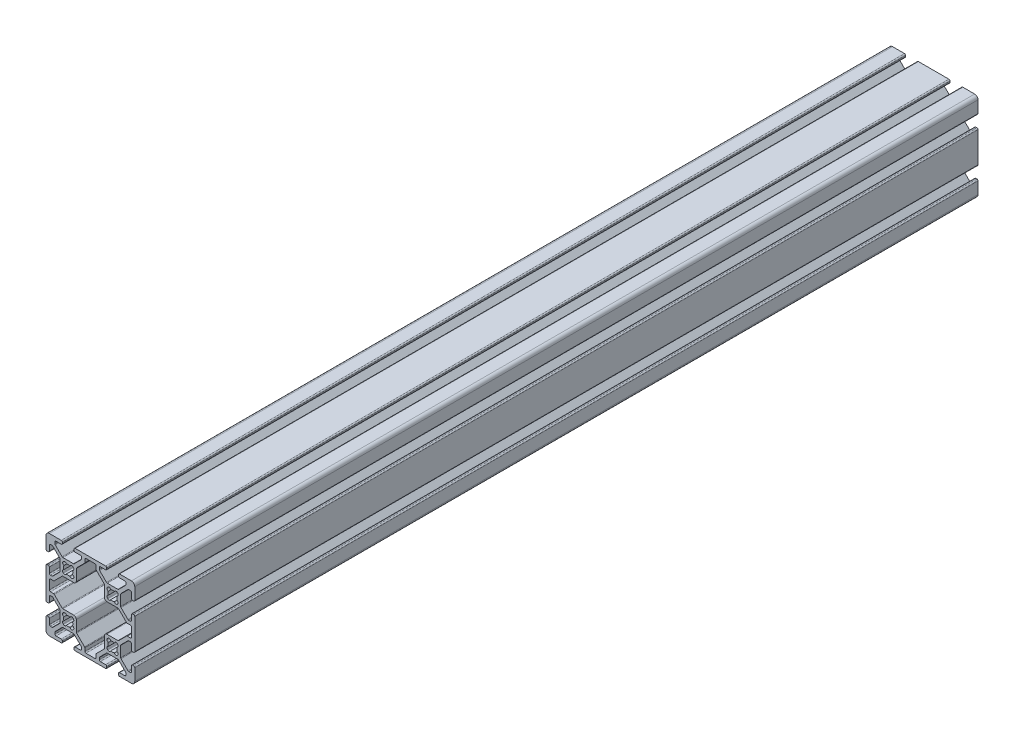
from build123d import *

# Parameters (mm, degrees)
EXTRUDE1_DEPTH = 380


with BuildPart() as part:
    # Sketch1 → Extrude1 (new body)
    with BuildSketch(Plane.XY):
        with BuildLine():
            Line((-22.383919339, -3.655), (-17.616080661, -3.655))
            ThreePointArc((-17.616080661, -3.655), (-17.421677478, -3.693669197), (-17.256870417, -3.803789755))
            Line((-17.256870417, -3.803789755), (-14.153789755, -6.906870417))
            ThreePointArc((-14.153789755, -6.906870417), (-14.043669197, -7.071677478), (-14.005, -7.266080661))
            Line((-14.005, -7.266080661), (-14.005, -7.992))
            ThreePointArc((-14.005, -7.992), (-14.153789755, -8.351210245), (-14.513, -8.5))
            Line((-14.513, -8.5), (-16.862, -8.5))
            ThreePointArc((-16.862, -8.5), (-17.221210245, -8.648789755), (-17.37, -9.008))
            Line((-17.37, -9.008), (-17.37, -9.492))
            ThreePointArc((-17.37, -9.492), (-17.221210245, -9.851210245), (-16.862, -10))
            Line((-16.862, -10), (-3.138, -10))
            ThreePointArc((-3.138, -10), (-2.778789755, -9.851210245), (-2.63, -9.492))
            Line((-2.63, -9.492), (-2.63, -9.008))
            ThreePointArc((-2.63, -9.008), (-2.778789755, -8.648789755), (-3.138, -8.5))
            Line((-3.138, -8.5), (-5.487, -8.5))
            ThreePointArc((-5.487, -8.5), (-5.846210245, -8.351210245), (-5.995, -7.992))
            Line((-5.995, -7.992), (-5.995, -7.266080661))
            ThreePointArc((-5.995, -7.266080661), (-5.956330803, -7.071677478), (-5.846210245, -6.906870417))
            Line((-5.846210245, -6.906870417), (-2.743129583, -3.803789755))
            ThreePointArc((-2.743129583, -3.803789755), (-2.578322522, -3.693669197), (-2.383919339, -3.655))
            Line((-2.383919339, -3.655), (2.383919339, -3.655))
            ThreePointArc((2.383919339, -3.655), (2.578322522, -3.693669197), (2.743129583, -3.803789755))
            Line((2.743129583, -3.803789755), (5.846210245, -6.906870417))
            ThreePointArc((5.846210245, -6.906870417), (5.956330803, -7.071677478), (5.995, -7.266080661))
            Line((5.995, -7.266080661), (5.995, -7.992))
            ThreePointArc((5.995, -7.992), (5.846210245, -8.351210245), (5.487, -8.5))
            Line((5.487, -8.5), (3.138, -8.5))
            ThreePointArc((3.138, -8.5), (2.778789755, -8.648789755), (2.63, -9.008))
            Line((2.63, -9.008), (2.63, -9.492))
            ThreePointArc((2.63, -9.492), (2.778789755, -9.851210245), (3.138, -10))
            Line((3.138, -10), (8.5, -10))
            ThreePointArc((8.5, -10), (9.560660172, -9.560660172), (10, -8.5))
            Line((10, -8.5), (10, -3.138))
            ThreePointArc((10, -3.138), (9.851210245, -2.778789755), (9.492, -2.63))
            Line((9.492, -2.63), (9.008, -2.63))
            ThreePointArc((9.008, -2.63), (8.648789755, -2.778789755), (8.5, -3.138))
            Line((8.5, -3.138), (8.5, -5.487))
            ThreePointArc((8.5, -5.487), (8.351210245, -5.846210245), (7.992, -5.995))
            Line((7.992, -5.995), (7.266080661, -5.995))
            ThreePointArc((7.266080661, -5.995), (7.071677478, -5.956330803), (6.906870417, -5.846210245))
            Line((6.906870417, -5.846210245), (3.803789755, -2.743129583))
            ThreePointArc((3.803789755, -2.743129583), (3.693669197, -2.578322522), (3.655, -2.383919339))
            Line((3.655, -2.383919339), (3.655, 2.383919339))
            ThreePointArc((3.655, 2.383919339), (3.693669197, 2.578322522), (3.803789755, 2.743129583))
            Line((3.803789755, 2.743129583), (6.906870417, 5.846210245))
            ThreePointArc((6.906870417, 5.846210245), (7.071677478, 5.956330803), (7.266080661, 5.995))
            Line((7.266080661, 5.995), (7.992, 5.995))
            ThreePointArc((7.992, 5.995), (8.351210245, 5.846210245), (8.5, 5.487))
            Line((8.5, 5.487), (8.5, 3.138))
            ThreePointArc((8.5, 3.138), (8.648789755, 2.778789755), (9.008, 2.63))
            Line((9.008, 2.63), (9.492, 2.63))
            ThreePointArc((9.492, 2.63), (9.851210245, 2.778789755), (10, 3.138))
            Line((10, 3.138), (10, 16.862))
            ThreePointArc((10, 16.862), (9.851210245, 17.221210245), (9.492, 17.37))
            Line((9.492, 17.37), (9.008, 17.37))
            ThreePointArc((9.008, 17.37), (8.648789755, 17.221210245), (8.5, 16.862))
            Line((8.5, 16.862), (8.5, 14.513))
            ThreePointArc((8.5, 14.513), (8.351210245, 14.153789755), (7.992, 14.005))
            Line((7.992, 14.005), (7.266080661, 14.005))
            ThreePointArc((7.266080661, 14.005), (7.071677478, 14.043669197), (6.906870417, 14.153789755))
            Line((6.906870417, 14.153789755), (3.803789755, 17.256870417))
            ThreePointArc((3.803789755, 17.256870417), (3.693669197, 17.421677478), (3.655, 17.616080661))
            Line((3.655, 17.616080661), (3.655, 22.383919339))
            ThreePointArc((3.655, 22.383919339), (3.693669197, 22.578322522), (3.803789755, 22.743129583))
            Line((3.803789755, 22.743129583), (6.906870417, 25.846210245))
            ThreePointArc((6.906870417, 25.846210245), (7.071677478, 25.956330803), (7.266080661, 25.995))
            Line((7.266080661, 25.995), (7.992, 25.995))
            ThreePointArc((7.992, 25.995), (8.351210245, 25.846210245), (8.5, 25.487))
            Line((8.5, 25.487), (8.5, 23.138))
            ThreePointArc((8.5, 23.138), (8.648789755, 22.778789755), (9.008, 22.63))
            Line((9.008, 22.63), (9.492, 22.63))
            ThreePointArc((9.492, 22.63), (9.851210245, 22.778789755), (10, 23.138))
            Line((10, 23.138), (10, 28.5))
            ThreePointArc((10, 28.5), (9.560660172, 29.560660172), (8.5, 30))
            Line((8.5, 30), (3.138, 30))
            ThreePointArc((3.138, 30), (2.778789755, 29.851210245), (2.63, 29.492))
            Line((2.63, 29.492), (2.63, 29.008))
            ThreePointArc((2.63, 29.008), (2.778789755, 28.648789755), (3.138, 28.5))
            Line((3.138, 28.5), (5.487, 28.5))
            ThreePointArc((5.487, 28.5), (5.846210245, 28.351210245), (5.995, 27.992))
            Line((5.995, 27.992), (5.995, 27.266080661))
            ThreePointArc((5.995, 27.266080661), (5.956330803, 27.071677478), (5.846210245, 26.906870417))
            Line((5.846210245, 26.906870417), (2.743129583, 23.803789755))
            ThreePointArc((2.743129583, 23.803789755), (2.578322522, 23.693669197), (2.383919339, 23.655))
            Line((2.383919339, 23.655), (-2.383919339, 23.655))
            ThreePointArc((-2.383919339, 23.655), (-2.578322522, 23.693669197), (-2.743129583, 23.803789755))
            Line((-2.743129583, 23.803789755), (-5.846210245, 26.906870417))
            ThreePointArc((-5.846210245, 26.906870417), (-5.956330803, 27.071677478), (-5.995, 27.266080661))
            Line((-5.995, 27.266080661), (-5.995, 27.992))
            ThreePointArc((-5.995, 27.992), (-5.846210245, 28.351210245), (-5.487, 28.5))
            Line((-5.487, 28.5), (-3.138, 28.5))
            ThreePointArc((-3.138, 28.5), (-2.778789755, 28.648789755), (-2.63, 29.008))
            Line((-2.63, 29.008), (-2.63, 29.492))
            ThreePointArc((-2.63, 29.492), (-2.778789755, 29.851210245), (-3.138, 30))
            Line((-3.138, 30), (-16.862, 30))
            ThreePointArc((-16.862, 30), (-17.221210245, 29.851210245), (-17.37, 29.492))
            Line((-17.37, 29.492), (-17.37, 29.008))
            ThreePointArc((-17.37, 29.008), (-17.221210245, 28.648789755), (-16.862, 28.5))
            Line((-16.862, 28.5), (-14.513, 28.5))
            ThreePointArc((-14.513, 28.5), (-14.153789755, 28.351210245), (-14.005, 27.992))
            Line((-14.005, 27.992), (-14.005, 27.266080661))
            ThreePointArc((-14.005, 27.266080661), (-14.043669197, 27.071677478), (-14.153789755, 26.906870417))
            Line((-14.153789755, 26.906870417), (-17.256870417, 23.803789755))
            ThreePointArc((-17.256870417, 23.803789755), (-17.421677478, 23.693669197), (-17.616080661, 23.655))
            Line((-17.616080661, 23.655), (-22.383919339, 23.655))
            ThreePointArc((-22.383919339, 23.655), (-22.578322522, 23.693669197), (-22.743129583, 23.803789755))
            Line((-22.743129583, 23.803789755), (-25.846210245, 26.906870417))
            ThreePointArc((-25.846210245, 26.906870417), (-25.956330803, 27.071677478), (-25.995, 27.266080661))
            Line((-25.995, 27.266080661), (-25.995, 27.992))
            ThreePointArc((-25.995, 27.992), (-25.846210245, 28.351210245), (-25.487, 28.5))
            Line((-25.487, 28.5), (-23.138, 28.5))
            ThreePointArc((-23.138, 28.5), (-22.778789755, 28.648789755), (-22.63, 29.008))
            Line((-22.63, 29.008), (-22.63, 29.492))
            ThreePointArc((-22.63, 29.492), (-22.778789755, 29.851210245), (-23.138, 30))
            Line((-23.138, 30), (-28.5, 30))
            ThreePointArc((-28.5, 30), (-29.560660172, 29.560660172), (-30, 28.5))
            Line((-30, 28.5), (-30, 23.138))
            ThreePointArc((-30, 23.138), (-29.851210245, 22.778789755), (-29.492, 22.63))
            Line((-29.492, 22.63), (-29.008, 22.63))
            ThreePointArc((-29.008, 22.63), (-28.648789755, 22.778789755), (-28.5, 23.138))
            Line((-28.5, 23.138), (-28.5, 25.487))
            ThreePointArc((-28.5, 25.487), (-28.351210245, 25.846210245), (-27.992, 25.995))
            Line((-27.992, 25.995), (-27.266080661, 25.995))
            ThreePointArc((-27.266080661, 25.995), (-27.071677478, 25.956330803), (-26.906870417, 25.846210245))
            Line((-26.906870417, 25.846210245), (-23.803789755, 22.743129583))
            ThreePointArc((-23.803789755, 22.743129583), (-23.693669197, 22.578322522), (-23.655, 22.383919339))
            Line((-23.655, 22.383919339), (-23.655, 17.616080661))
            ThreePointArc((-23.655, 17.616080661), (-23.693669197, 17.421677478), (-23.803789755, 17.256870417))
            Line((-23.803789755, 17.256870417), (-26.906870417, 14.153789755))
            ThreePointArc((-26.906870417, 14.153789755), (-27.071677478, 14.043669197), (-27.266080661, 14.005))
            Line((-27.266080661, 14.005), (-27.992, 14.005))
            ThreePointArc((-27.992, 14.005), (-28.351210245, 14.153789755), (-28.5, 14.513))
            Line((-28.5, 14.513), (-28.5, 16.862))
            ThreePointArc((-28.5, 16.862), (-28.648789755, 17.221210245), (-29.008, 17.37))
            Line((-29.008, 17.37), (-29.492, 17.37))
            ThreePointArc((-29.492, 17.37), (-29.851210245, 17.221210245), (-30, 16.862))
            Line((-30, 16.862), (-30, 3.138))
            ThreePointArc((-30, 3.138), (-29.851210245, 2.778789755), (-29.492, 2.63))
            Line((-29.492, 2.63), (-29.008, 2.63))
            ThreePointArc((-29.008, 2.63), (-28.648789755, 2.778789755), (-28.5, 3.138))
            Line((-28.5, 3.138), (-28.5, 5.487))
            ThreePointArc((-28.5, 5.487), (-28.351210245, 5.846210245), (-27.992, 5.995))
            Line((-27.992, 5.995), (-27.266080661, 5.995))
            ThreePointArc((-27.266080661, 5.995), (-27.071677478, 5.956330803), (-26.906870417, 5.846210245))
            Line((-26.906870417, 5.846210245), (-23.803789755, 2.743129583))
            ThreePointArc((-23.803789755, 2.743129583), (-23.693669197, 2.578322522), (-23.655, 2.383919339))
            Line((-23.655, 2.383919339), (-23.655, -2.383919339))
            ThreePointArc((-23.655, -2.383919339), (-23.693669197, -2.578322522), (-23.803789755, -2.743129583))
            Line((-23.803789755, -2.743129583), (-26.906870417, -5.846210245))
            ThreePointArc((-26.906870417, -5.846210245), (-27.071677478, -5.956330803), (-27.266080661, -5.995))
            Line((-27.266080661, -5.995), (-27.992, -5.995))
            ThreePointArc((-27.992, -5.995), (-28.351210245, -5.846210245), (-28.5, -5.487))
            Line((-28.5, -5.487), (-28.5, -3.138))
            ThreePointArc((-28.5, -3.138), (-28.648789755, -2.778789755), (-29.008, -2.63))
            Line((-29.008, -2.63), (-29.492, -2.63))
            ThreePointArc((-29.492, -2.63), (-29.851210245, -2.778789755), (-30, -3.138))
            Line((-30, -3.138), (-30, -8.5))
            ThreePointArc((-30, -8.5), (-29.560660172, -9.560660172), (-28.5, -10))
            Line((-28.5, -10), (-23.138, -10))
            ThreePointArc((-23.138, -10), (-22.778789755, -9.851210245), (-22.63, -9.492))
            Line((-22.63, -9.492), (-22.63, -9.008))
            ThreePointArc((-22.63, -9.008), (-22.778789755, -8.648789755), (-23.138, -8.5))
            Line((-23.138, -8.5), (-25.487, -8.5))
            ThreePointArc((-25.487, -8.5), (-25.846210245, -8.351210245), (-25.995, -7.992))
            Line((-25.995, -7.992), (-25.995, -7.266080661))
            ThreePointArc((-25.995, -7.266080661), (-25.956330803, -7.071677478), (-25.846210245, -6.906870417))
            Line((-25.846210245, -6.906870417), (-22.743129583, -3.803789755))
            ThreePointArc((-22.743129583, -3.803789755), (-22.578322522, -3.693669197), (-22.383919339, -3.655))
        make_face()
        with BuildLine():
            Line((-2.124900844, 17.695494034), (-2.304505966, 17.875099156))
            ThreePointArc((-2.304505966, 17.875099156), (-2.505938017, 18.643532189), (-1.935133506, 19.196023282))
            ThreePointArc((-1.935133506, 19.196023282), (-2.0955, 20), (-1.935133506, 20.803976718))
            ThreePointArc((-1.935133506, 20.803976718), (-2.505938017, 21.356467811), (-2.304505966, 22.124900844))
            Line((-2.304505966, 22.124900844), (-2.124900844, 22.304505966))
            ThreePointArc((-2.124900844, 22.304505966), (-1.356467811, 22.505938017), (-0.803976718, 21.935133506))
            ThreePointArc((-0.803976718, 21.935133506), (0, 22.0955), (0.803976718, 21.935133506))
            ThreePointArc((0.803976718, 21.935133506), (1.356467811, 22.505938017), (2.124900844, 22.304505966))
            Line((2.124900844, 22.304505966), (2.304505966, 22.124900844))
            ThreePointArc((2.304505966, 22.124900844), (2.505938017, 21.356467811), (1.935133506, 20.803976718))
            ThreePointArc((1.935133506, 20.803976718), (2.0955, 20), (1.935133506, 19.196023282))
            ThreePointArc((1.935133506, 19.196023282), (2.505938017, 18.643532189), (2.304505966, 17.875099156))
            Line((2.304505966, 17.875099156), (2.124900844, 17.695494034))
            ThreePointArc((2.124900844, 17.695494034), (1.356467811, 17.494061983), (0.803976718, 18.064866494))
            ThreePointArc((0.803976718, 18.064866494), (0, 17.9045), (-0.803976718, 18.064866494))
            ThreePointArc((-0.803976718, 18.064866494), (-1.356467811, 17.494061983), (-2.124900844, 17.695494034))
        make_face(mode=Mode.SUBTRACT)
        with BuildLine():
            Line((-22.124900844, 17.695494034), (-22.304505966, 17.875099156))
            ThreePointArc((-22.304505966, 17.875099156), (-22.505938017, 18.643532189), (-21.935133506, 19.196023282))
            ThreePointArc((-21.935133506, 19.196023282), (-22.0955, 20), (-21.935133506, 20.803976718))
            ThreePointArc((-21.935133506, 20.803976718), (-22.505938017, 21.356467811), (-22.304505966, 22.124900844))
            Line((-22.304505966, 22.124900844), (-22.124900844, 22.304505966))
            ThreePointArc((-22.124900844, 22.304505966), (-21.356467811, 22.505938017), (-20.803976718, 21.935133506))
            ThreePointArc((-20.803976718, 21.935133506), (-20, 22.0955), (-19.196023282, 21.935133506))
            ThreePointArc((-19.196023282, 21.935133506), (-18.643532189, 22.505938017), (-17.875099156, 22.304505966))
            Line((-17.875099156, 22.304505966), (-17.695494034, 22.124900844))
            ThreePointArc((-17.695494034, 22.124900844), (-17.494061983, 21.356467811), (-18.064866494, 20.803976718))
            ThreePointArc((-18.064866494, 20.803976718), (-17.9045, 20), (-18.064866494, 19.196023282))
            ThreePointArc((-18.064866494, 19.196023282), (-17.494061983, 18.643532189), (-17.695494034, 17.875099156))
            Line((-17.695494034, 17.875099156), (-17.875099156, 17.695494034))
            ThreePointArc((-17.875099156, 17.695494034), (-18.643532189, 17.494061983), (-19.196023282, 18.064866494))
            ThreePointArc((-19.196023282, 18.064866494), (-20, 17.9045), (-20.803976718, 18.064866494))
            ThreePointArc((-20.803976718, 18.064866494), (-21.356467811, 17.494061983), (-22.124900844, 17.695494034))
        make_face(mode=Mode.SUBTRACT)
        with BuildLine():
            Line((-2.124900844, -2.304505966), (-2.304505966, -2.124900844))
            ThreePointArc((-2.304505966, -2.124900844), (-2.505938017, -1.356467811), (-1.935133506, -0.803976718))
            ThreePointArc((-1.935133506, -0.803976718), (-2.0955, 0), (-1.935133506, 0.803976718))
            ThreePointArc((-1.935133506, 0.803976718), (-2.505938017, 1.356467811), (-2.304505966, 2.124900844))
            Line((-2.304505966, 2.124900844), (-2.124900844, 2.304505966))
            ThreePointArc((-2.124900844, 2.304505966), (-1.356467811, 2.505938017), (-0.803976718, 1.935133506))
            ThreePointArc((-0.803976718, 1.935133506), (0, 2.0955), (0.803976718, 1.935133506))
            ThreePointArc((0.803976718, 1.935133506), (1.356467811, 2.505938017), (2.124900844, 2.304505966))
            Line((2.124900844, 2.304505966), (2.304505966, 2.124900844))
            ThreePointArc((2.304505966, 2.124900844), (2.505938017, 1.356467811), (1.935133506, 0.803976718))
            ThreePointArc((1.935133506, 0.803976718), (2.0955, 0), (1.935133506, -0.803976718))
            ThreePointArc((1.935133506, -0.803976718), (2.505938017, -1.356467811), (2.304505966, -2.124900844))
            Line((2.304505966, -2.124900844), (2.124900844, -2.304505966))
            ThreePointArc((2.124900844, -2.304505966), (1.356467811, -2.505938017), (0.803976718, -1.935133506))
            ThreePointArc((0.803976718, -1.935133506), (0, -2.0955), (-0.803976718, -1.935133506))
            ThreePointArc((-0.803976718, -1.935133506), (-1.356467811, -2.505938017), (-2.124900844, -2.304505966))
        make_face(mode=Mode.SUBTRACT)
        with BuildLine():
            Line((-12.505, -7.992), (-12.505, -6.644760318))
            ThreePointArc((-12.505, -6.644760318), (-12.543669197, -6.450357134), (-12.653789755, -6.285550073))
            Line((-12.653789755, -6.285550073), (-16.196210245, -2.743129583))
            ThreePointArc((-16.196210245, -2.743129583), (-16.306330803, -2.578322522), (-16.345, -2.383919339))
            Line((-16.345, -2.383919339), (-16.345, 2.512))
            ThreePointArc((-16.345, 2.512), (-16.679776949, 3.320223051), (-17.488, 3.655))
            Line((-17.488, 3.655), (-22.383919339, 3.655))
            ThreePointArc((-22.383919339, 3.655), (-22.578322522, 3.693669197), (-22.743129583, 3.803789755))
            Line((-22.743129583, 3.803789755), (-26.285550073, 7.346210245))
            ThreePointArc((-26.285550073, 7.346210245), (-26.450357134, 7.456330803), (-26.644760318, 7.495))
            Line((-26.644760318, 7.495), (-27.992, 7.495))
            ThreePointArc((-27.992, 7.495), (-28.351210245, 7.643789755), (-28.5, 8.003))
            Line((-28.5, 8.003), (-28.5, 11.997))
            ThreePointArc((-28.5, 11.997), (-28.351210245, 12.356210245), (-27.992, 12.505))
            Line((-27.992, 12.505), (-26.644760318, 12.505))
            ThreePointArc((-26.644760318, 12.505), (-26.450357134, 12.543669197), (-26.285550073, 12.653789755))
            Line((-26.285550073, 12.653789755), (-22.743129583, 16.196210245))
            ThreePointArc((-22.743129583, 16.196210245), (-22.578322522, 16.306330803), (-22.383919339, 16.345))
            Line((-22.383919339, 16.345), (-17.488, 16.345))
            ThreePointArc((-17.488, 16.345), (-16.679776949, 16.679776949), (-16.345, 17.488))
            Line((-16.345, 17.488), (-16.345, 22.383919339))
            ThreePointArc((-16.345, 22.383919339), (-16.306330803, 22.578322522), (-16.196210245, 22.743129583))
            Line((-16.196210245, 22.743129583), (-12.653789755, 26.285550073))
            ThreePointArc((-12.653789755, 26.285550073), (-12.543669197, 26.450357134), (-12.505, 26.644760318))
            Line((-12.505, 26.644760318), (-12.505, 27.992))
            ThreePointArc((-12.505, 27.992), (-12.356210245, 28.351210245), (-11.997, 28.5))
            Line((-11.997, 28.5), (-8.003, 28.5))
            ThreePointArc((-8.003, 28.5), (-7.643789755, 28.351210245), (-7.495, 27.992))
            Line((-7.495, 27.992), (-7.495, 26.644760318))
            ThreePointArc((-7.495, 26.644760318), (-7.456330803, 26.450357134), (-7.346210245, 26.285550073))
            Line((-7.346210245, 26.285550073), (-3.803789755, 22.743129583))
            ThreePointArc((-3.803789755, 22.743129583), (-3.693669197, 22.578322522), (-3.655, 22.383919339))
            Line((-3.655, 22.383919339), (-3.655, 17.488))
            ThreePointArc((-3.655, 17.488), (-3.320223051, 16.679776949), (-2.512, 16.345))
            Line((-2.512, 16.345), (2.383919339, 16.345))
            ThreePointArc((2.383919339, 16.345), (2.578322522, 16.306330803), (2.743129583, 16.196210245))
            Line((2.743129583, 16.196210245), (6.285550073, 12.653789755))
            ThreePointArc((6.285550073, 12.653789755), (6.450357134, 12.543669197), (6.644760318, 12.505))
            Line((6.644760318, 12.505), (7.992, 12.505))
            ThreePointArc((7.992, 12.505), (8.351210245, 12.356210245), (8.5, 11.997))
            Line((8.5, 11.997), (8.5, 8.003))
            ThreePointArc((8.5, 8.003), (8.351210245, 7.643789755), (7.992, 7.495))
            Line((7.992, 7.495), (6.644760318, 7.495))
            ThreePointArc((6.644760318, 7.495), (6.450357134, 7.456330803), (6.285550073, 7.346210245))
            Line((6.285550073, 7.346210245), (2.743129583, 3.803789755))
            ThreePointArc((2.743129583, 3.803789755), (2.578322522, 3.693669197), (2.383919339, 3.655))
            Line((2.383919339, 3.655), (-2.512, 3.655))
            ThreePointArc((-2.512, 3.655), (-3.320223051, 3.320223051), (-3.655, 2.512))
            Line((-3.655, 2.512), (-3.655, -2.383919339))
            ThreePointArc((-3.655, -2.383919339), (-3.693669197, -2.578322522), (-3.803789755, -2.743129583))
            Line((-3.803789755, -2.743129583), (-7.346210245, -6.285550073))
            ThreePointArc((-7.346210245, -6.285550073), (-7.456330803, -6.450357134), (-7.495, -6.644760318))
            Line((-7.495, -6.644760318), (-7.495, -7.992))
            ThreePointArc((-7.495, -7.992), (-7.643789755, -8.351210245), (-8.003, -8.5))
            Line((-8.003, -8.5), (-11.997, -8.5))
            ThreePointArc((-11.997, -8.5), (-12.356210245, -8.351210245), (-12.505, -7.992))
        make_face(mode=Mode.SUBTRACT)
        with BuildLine():
            Line((-22.124900844, -2.304505966), (-22.304505966, -2.124900844))
            ThreePointArc((-22.304505966, -2.124900844), (-22.505938017, -1.356467811), (-21.935133506, -0.803976718))
            ThreePointArc((-21.935133506, -0.803976718), (-22.0955, 0), (-21.935133506, 0.803976718))
            ThreePointArc((-21.935133506, 0.803976718), (-22.505938017, 1.356467811), (-22.304505966, 2.124900844))
            Line((-22.304505966, 2.124900844), (-22.124900844, 2.304505966))
            ThreePointArc((-22.124900844, 2.304505966), (-21.356467811, 2.505938017), (-20.803976718, 1.935133506))
            ThreePointArc((-20.803976718, 1.935133506), (-20, 2.0955), (-19.196023282, 1.935133506))
            ThreePointArc((-19.196023282, 1.935133506), (-18.643532189, 2.505938017), (-17.875099156, 2.304505966))
            Line((-17.875099156, 2.304505966), (-17.695494034, 2.124900844))
            ThreePointArc((-17.695494034, 2.124900844), (-17.494061983, 1.356467811), (-18.064866494, 0.803976718))
            ThreePointArc((-18.064866494, 0.803976718), (-17.9045, 0), (-18.064866494, -0.803976718))
            ThreePointArc((-18.064866494, -0.803976718), (-17.494061983, -1.356467811), (-17.695494034, -2.124900844))
            Line((-17.695494034, -2.124900844), (-17.875099156, -2.304505966))
            ThreePointArc((-17.875099156, -2.304505966), (-18.643532189, -2.505938017), (-19.196023282, -1.935133506))
            ThreePointArc((-19.196023282, -1.935133506), (-20, -2.0955), (-20.803976718, -1.935133506))
            ThreePointArc((-20.803976718, -1.935133506), (-21.356467811, -2.505938017), (-22.124900844, -2.304505966))
        make_face(mode=Mode.SUBTRACT)
    extrude(amount=-EXTRUDE1_DEPTH)


solid = part.part
